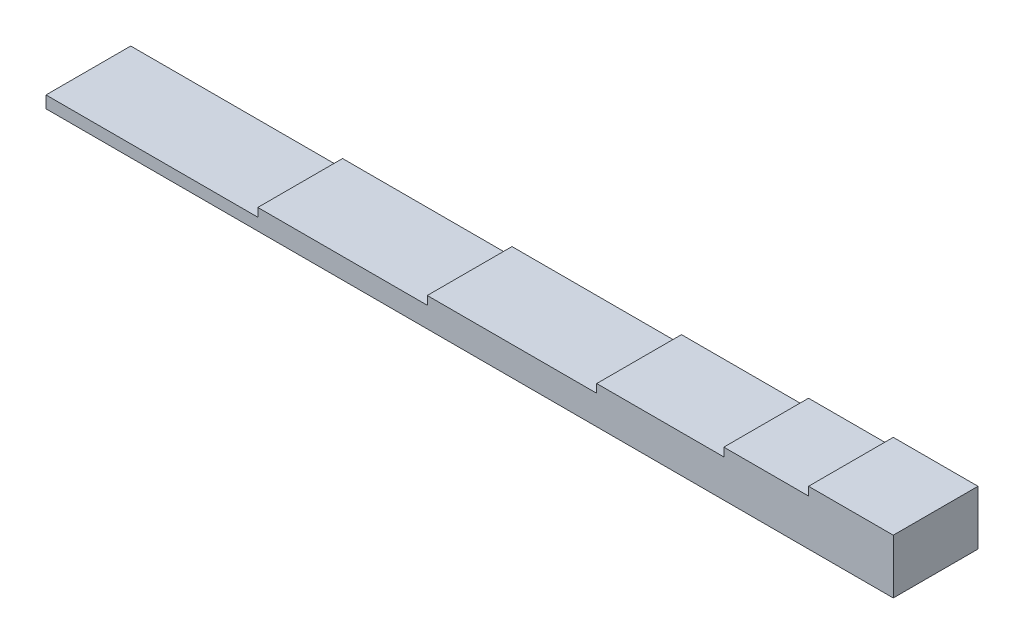
from build123d import *

# Parameters (mm, degrees)
BOSS_EXTRUDE2_DEPTH = 10


with BuildPart() as part:
    # Sketch2 → Boss-Extrude2 (new body)
    with BuildSketch(Plane.XY):
        Polygon((20, 0), (0, 0), (0, -1), (-25, -1), (-25, -2.421519289), (75, -2.421519289), (75, 4), (65, 4), (65, 3), (55, 3), (55, 2), (40, 2), (40, 1), (20, 1), align=None)
    extrude(amount=BOSS_EXTRUDE2_DEPTH)


solid = part.part
